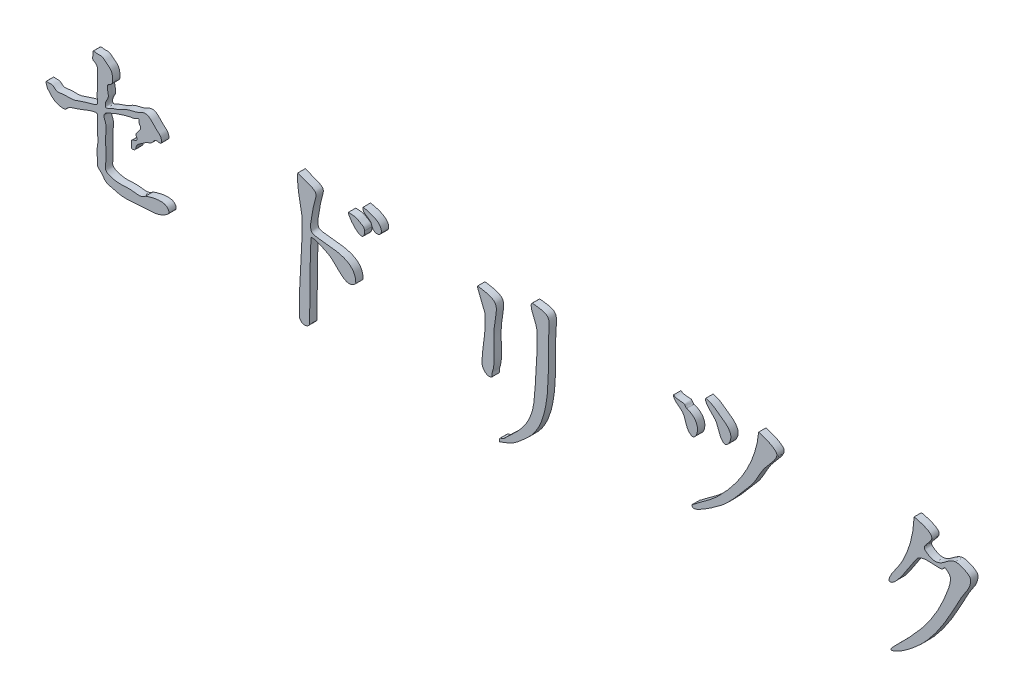
from build123d import *

# Parameters (mm, degrees)
BOSS_EXTRU_1_DEPTH    = 10
BOSS_EXTRU_1_2_DEPTH  = 10
BOSS_EXTRU_1_3_DEPTH  = 10
BOSS_EXTRU_1_4_DEPTH  = 10
BOSS_EXTRU_1_5_DEPTH  = 10
BOSS_EXTRU_1_6_DEPTH  = 10
BOSS_EXTRU_1_7_DEPTH  = 10
BOSS_EXTRU_1_8_DEPTH  = 10
BOSS_EXTRU_1_9_DEPTH  = 10
BOSS_EXTRU_1_10_DEPTH = 10


with BuildPart() as part:
    # Esquisse2 → Boss.-Extru.1 (new body)
    with BuildSketch(Plane.XY):
        with BuildLine():
            add(Edge.make_bspline(
                [(432.080750122, 148.838499756), (430.771768336, 149.257373927), (428.160674934, 149.210542362), (428.080750122, 147.838499756), (426.103139416, 113.889515966), (427.07081187, 79.830619757), (426.080750122, 45.838499756), (425.989196898, 42.695172395), (421.144879507, 40.131392974), (418.080750122, 40.838499756), (415.08626914, 41.529533829), (412.129914733, 44.765711562), (412.080750122, 47.838499756), (411.451135896, 87.189388879), (416.328266772, 126.483352387), (416.080750122, 165.838499756), (416.07848798, 166.198180437), (407.615717471, 203.513336499), (410.080750122, 215.838499756)],
                knots=[6, 6, 6, 6, 7, 7, 7, 8, 8, 8, 9, 9, 9, 10, 10, 10, 11, 11, 11, 12, 12, 12, 12], degree=3))
            add(Edge.make_bspline(
                [(410.080750122, 215.838499756), (444.705544929, 203.247665281), (434.174591037, 207.813079343), (430.080750122, 179.838499756), (428.966433901, 172.224005578), (426.350321845, 164.33702229), (428.080750122, 156.838499756), (430.502416465, 146.344612272), (489.080750122, 160.294699575), (489.080750122, 124.838499756), (489.080750122, 124.367095235), (488.414083456, 124.171833089), (488.080750122, 123.838499756), (475.6538721, 111.411621734), (464.034223561, 132.960737364), (453.080750122, 139.838499756), (446.631028121, 143.888325198), (439.334196328, 146.51739697), (432.080750122, 148.838499756)],
                knots=[0, 0, 0, 0, 1, 1, 1, 2, 2, 2, 3, 3, 3, 4, 4, 4, 5, 5, 5, 6, 6, 6, 6], degree=3))
        make_face()
    extrude(amount=BOSS_EXTRU_1_DEPTH)


with BuildPart() as body_2:
    # Esquisse2 → Boss.-Extru.1 2 (new body)
    with BuildSketch(Plane.XY):
        with BuildLine():
            add(Edge.make_bspline(
                [(501.080750122, 192.838499756), (501.080750122, 171.074934244), (477.871223683, 199.000393997), (479.080750122, 203.838499756)],
                knots=[2, 2, 2, 2, 3, 3, 3, 3], degree=3))
            add(Edge.make_bspline(
                [(479.080750122, 203.838499756), (487.057047526, 203.11338181), (488.454293708, 203.922804032), (493.080750122, 200.838499756), (495.862376364, 198.984082261), (501.080750122, 197.4302739), (501.080750122, 192.838499756)],
                knots=[0, 0, 0, 0, 1, 1, 1, 2, 2, 2, 2], degree=3))
        make_face()
    extrude(amount=BOSS_EXTRU_1_2_DEPTH)


with BuildPart() as body_3:
    # Esquisse2 → Boss.-Extru.1 3 (new body)
    with BuildSketch(Plane.XY):
        with BuildLine():
            add(Edge.make_bspline(
                [(513.080750122, 199.838499756), (512.204955469, 200.539135478), (510.08020419, 206.839045688), (509.080750122, 207.838499756), (504.113950608, 212.80529927), (497.444544286, 213.293676412), (499.080750122, 219.838499756)],
                knots=[2, 2, 2, 2, 3, 3, 3, 4, 4, 4, 4], degree=3))
            add(Edge.make_bspline(
                [(499.080750122, 219.838499756), (504.643768447, 219.043782852), (513.169320977, 216.446119186), (517.080750122, 213.838499756), (530.447689072, 204.927207123), (521.54230902, 193.069252638), (513.080750122, 199.838499756)],
                knots=[0, 0, 0, 0, 1, 1, 1, 2, 2, 2, 2], degree=3))
        make_face()
    extrude(amount=BOSS_EXTRU_1_3_DEPTH)


with BuildPart() as body_4:
    # Esquisse2 → Boss.-Extru.1 4 (new body)
    with BuildSketch(Plane.XY):
        with BuildLine():
            add(Edge.make_bspline(
                [(674.080750122, 106.838499756), (667.289356089, 103.442802739), (661.080750122, 111.57228509), (661.080750122, 116.838499756), (661.080750122, 137.300377055), (667.220707502, 155.438925958), (665.080750122, 176.838499756), (664.454868291, 183.097318069), (654.002069655, 201.602458354), (655.080750122, 204.838499756)],
                knots=[3, 3, 3, 3, 4, 4, 4, 5, 5, 5, 6, 6, 6, 6], degree=3))
            add(Edge.make_bspline(
                [(655.080750122, 204.838499756), (693.790665267, 199.999760362), (677.080750122, 190.236665998), (677.080750122, 155.838499756), (677.080750122, 141.489670922), (679.618248209, 126.450994016), (675.080750122, 112.838499756), (674.439570653, 110.914961349), (675.894279523, 107.745264456), (674.080750122, 106.838499756)],
                knots=[0, 0, 0, 0, 1, 1, 1, 2, 2, 2, 3, 3, 3, 3], degree=3))
        make_face()
    extrude(amount=BOSS_EXTRU_1_4_DEPTH)


with BuildPart() as body_5:
    # Esquisse2 → Boss.-Extru.1 5 (new body)
    with BuildSketch(Plane.XY):
        with BuildLine():
            add(Edge.make_bspline(
                [(736.080750122, 190.838499756), (735.878931153, 200.223081804), (729.014766845, 208.498332526), (728.080750122, 217.838499756), (727.932418736, 219.321813621), (728.596160184, 221.973462477), (730.080750122, 221.838499756), (754.103191948, 219.654641408), (753.407702976, 216.088886857), (752.080750122, 198.838499756), (749.218452305, 161.628628129), (759.794035762, 94.170899687), (724.080750122, 60.838499756), (704.106463227, 42.195831987), (701.944808029, 42.162521471), (685.080750122, 35.838499756)],
                knots=[5, 5, 5, 5, 6, 6, 6, 7, 7, 7, 8, 8, 8, 9, 9, 9, 10, 10, 10, 10], degree=3))
            add(Edge.make_bspline(
                [(685.080750122, 35.838499756), (685.080750122, 37.171833089), (684.213028291, 38.826157619), (685.080750122, 39.838499756), (686.535963872, 41.536249131), (689.450996288, 41.307518881), (691.080750122, 42.838499756), (708.258288838, 58.974975519), (722.092336613, 70.475576526), (729.080750122, 92.838499756), (731.696213461, 101.20798244), (732.456011034, 110.09215252), (733.080750122, 118.838499756), (734.792162992, 142.79827993), (736.597207577, 166.823228121), (736.080750122, 190.838499756)],
                knots=[0, 0, 0, 0, 1, 1, 1, 2, 2, 2, 3, 3, 3, 4, 4, 4, 5, 5, 5, 5], degree=3))
        make_face()
    extrude(amount=BOSS_EXTRU_1_5_DEPTH)


with BuildPart() as body_6:
    # Esquisse2 → Boss.-Extru.1 6 (new body)
    with BuildSketch(Plane.XY):
        with BuildLine():
            add(Edge.make_bspline(
                [(940.080750122, 202.838499756), (963.17137518, 195.141624736), (953.749672127, 171.170930954), (947.080750122, 173.838499756), (938.475268795, 177.280692286), (939.331320695, 190.004532453), (934.080750122, 195.838499756), (929.969050066, 200.407055373), (922.080750122, 203.692136784), (922.080750122, 209.838499756)],
                knots=[3, 3, 3, 3, 4, 4, 4, 5, 5, 5, 6, 6, 6, 6], degree=3))
            add(Edge.make_bspline(
                [(922.080750122, 209.838499756), (923.526953174, 209.476948993), (924.618986757, 208.130852429), (926.080750122, 207.838499756), (929.365654731, 207.181518834), (932.795845513, 207.495480677), (936.080750122, 206.838499756), (937.929750776, 206.468699625), (938.29189574, 203.43478455), (940.080750122, 202.838499756)],
                knots=[0, 0, 0, 0, 1, 1, 1, 2, 2, 2, 3, 3, 3, 3], degree=3))
        make_face()
    extrude(amount=BOSS_EXTRU_1_6_DEPTH)


with BuildPart() as body_7:
    # Esquisse2 → Boss.-Extru.1 7 (new body)
    with BuildSketch(Plane.XY):
        with BuildLine():
            add(Edge.make_bspline(
                [(992.080750122, 186.838499756), (984.701047098, 188.314440361), (983.107646144, 203.804879729), (979.080750122, 208.838499756), (975.412277877, 213.424090062), (963.492058054, 222.661115618), (966.080750122, 227.838499756)],
                knots=[3, 3, 3, 3, 4, 4, 4, 5, 5, 5, 5], degree=3))
            add(Edge.make_bspline(
                [(966.080750122, 227.838499756), (970.869560247, 227.040364735), (975.579325444, 224.464568264), (979.080750122, 221.838499756), (989.344386267, 214.140772647), (1007.612519731, 205.636154168), (997.080750122, 189.838499756), (996.002606735, 188.221284676), (993.986656372, 186.457318506), (992.080750122, 186.838499756)],
                knots=[0, 0, 0, 0, 1, 1, 1, 2, 2, 2, 3, 3, 3, 3], degree=3))
        make_face()
    extrude(amount=BOSS_EXTRU_1_7_DEPTH)


with BuildPart() as body_8:
    # Esquisse2 → Boss.-Extru.1 8 (new body)
    with BuildSketch(Plane.XY):
        with BuildLine():
            add(Edge.make_bspline(
                [(973.080750122, 101.838499756), (955.315186437, 89.994790632), (948.013809326, 87.173203736), (947.080750122, 91.838499756), (946.803400024, 93.225250246), (948.976434861, 93.955047547), (950.080750122, 94.838499756), (960.650559355, 103.294347142), (972.348551982, 110.43070822), (982.080750122, 119.838499756), (1009.938524835, 146.767681978), (1034.787048033, 184.314074681), (1038.080750122, 223.838499756)],
                knots=[5, 5, 5, 5, 6, 6, 6, 7, 7, 7, 8, 8, 8, 9, 9, 9, 9], degree=3))
            add(Edge.make_bspline(
                [(1038.080750122, 223.838499756), (1045.199518492, 221.702869245), (1057.480519018, 217.972141228), (1062.080750122, 211.838499756), (1066.673561297, 205.714751523), (1051.038800565, 192.425101864), (1045.080750122, 183.838499756), (1038.332778104, 174.113481259), (1033.929001475, 162.699428703), (1026.080750122, 153.838499756), (1016.059384312, 142.524054486), (1006.869526062, 130.423713885), (996.080750122, 119.838499756), (989.13154495, 113.020411662), (981.181082499, 107.23872134), (973.080750122, 101.838499756)],
                knots=[0, 0, 0, 0, 1, 1, 1, 2, 2, 2, 3, 3, 3, 4, 4, 4, 5, 5, 5, 5], degree=3))
        make_face()
    extrude(amount=BOSS_EXTRU_1_8_DEPTH)


with BuildPart() as body_9:
    # Esquisse2 → Boss.-Extru.1 9 (new body)
    with BuildSketch(Plane.XY):
        with BuildLine():
            add(Edge.make_bspline(
                [(1224.080750122, 64.838499756), (1252.215254444, 92.25160653), (1275.58949357, 117.148681605), (1291.080750122, 153.838499756), (1293.564238109, 159.720444987), (1303.010193511, 180.416112028), (1298.080750122, 185.838499756), (1289.217417241, 195.588165925), (1291.619869973, 187.372513856), (1287.080750122, 186.838499756), (1276.440691586, 185.586728163), (1263.788816934, 190.079280971), (1255.080750122, 183.838499756), (1251.084404882, 180.974452333), (1226.944021253, 135.742580741), (1217.080750122, 136.838499756), (1214.409767842, 137.135275565), (1216.850028768, 142.44945242), (1218.080750122, 144.838499756), (1222.611718301, 153.633908572), (1229.592063931, 161.021437594), (1234.080750122, 169.838499756), (1244.88089933, 191.053078558), (1248.667479067, 207.226162876), (1250.080750122, 229.838499756)],
                knots=[8, 8, 8, 8, 9, 9, 9, 10, 10, 10, 11, 11, 11, 12, 12, 12, 13, 13, 13, 14, 14, 14, 15, 15, 15, 16, 16, 16, 16], degree=3))
            add(Edge.make_bspline(
                [(1250.080750122, 229.838499756), (1251.63022695, 229.39579209), (1274.671840414, 224.522673553), (1274.080750122, 216.838499756), (1273.543266272, 209.851209707), (1259.63387091, 202.247878165), (1265.080750122, 197.838499756), (1288.594478386, 178.803576875), (1294.053216135, 211.156782059), (1313.080750122, 203.838499756), (1318.619998813, 201.70801949), (1327.225459068, 198.771566546), (1327.080750122, 192.838499756), (1326.808139979, 181.661483888), (1317.190935402, 172.782644083), (1312.080750122, 162.838499756), (1297.798211422, 135.045451475), (1282.35835008, 106.750893157), (1260.080750122, 84.838499756), (1257.003927061, 81.812116417), (1232.763305727, 59.326237138), (1219.080750122, 56.838499756), (1215.986813399, 56.275965806), (1221.828451315, 62.6439522), (1224.080750122, 64.838499756)],
                knots=[0, 0, 0, 0, 1, 1, 1, 2, 2, 2, 3, 3, 3, 4, 4, 4, 5, 5, 5, 6, 6, 6, 7, 7, 7, 8, 8, 8, 8], degree=3))
        make_face()
    extrude(amount=BOSS_EXTRU_1_9_DEPTH)


with BuildPart() as body_10:
    # Esquisse2 → Boss.-Extru.1 10 (new body)
    with BuildSketch(Plane.XY):
        with BuildLine():
            add(Edge.make_bspline(
                [(71.075421494, 142.959669144), (75.406675635, 135.430914206), (84.661989741, 131.023884336), (93.27491994, 132.328923409)],
                knots=[0, 0, 0, 0, 1, 1, 1, 1], degree=3))
            add(Edge.make_bspline(
                [(93.27491994, 132.328923409), (97.153171329, 137.994252064), (107.023213135, 139.838831977), (120.173743393, 145.316717918), (127.968837828, 148.388726831), (138.30283699, 150.425636976), (136.770992635, 142.913375551), (137.186551016, 136.963712563), (136.916085129, 129.779783374), (137.390356099, 121.714122438), (137.843535079, 112.450940635), (134.837115301, 102.883049635), (138.193176702, 94.726521633), (135.799033141, 86.893182778), (143.496797881, 82.195390001), (146.993916264, 74.227627079), (157.324418811, 71.420805191), (169.925170552, 67.713330583), (185.312146892, 68.590210636), (201.749977897, 70.174322762), (216.571175565, 69.918745365), (227.431899373, 74.562426573), (236.029745364, 80.080180203), (231.553836718, 88.193531584), (218.765102194, 89.784986439), (209.20983219, 86.868303511), (202.396398216, 84.490567603)],
                knots=[0, 0, 0, 0, 0.073359985, 0.118542653, 0.164390314, 0.187974318, 0.211345649, 0.231205862, 0.264719973, 0.294536142, 0.328050253, 0.374882197, 0.408127887, 0.42926584, 0.461847526, 0.498877971, 0.528382464, 0.581972851, 0.657689916, 0.707479896, 0.780976943, 0.826617642, 0.856459637, 0.879780858, 0.914735151, 1, 1, 1, 1], degree=3))
            add(Edge.make_bspline(
                [(202.396398216, 84.490567603), (196.733973172, 79.203641418), (186.837765677, 82.529970664), (173.678562052, 82.000231605), (163.91422851, 81.472700362), (155.483881866, 83.517652811), (146.421042021, 87.319148653), (148.975811592, 97.474429661), (148.04972989, 107.152468006), (148.519285783, 119.072474377), (147.720380765, 131.069908577), (149.978632752, 142.420375593), (144.361521102, 150.652434662), (148.158232805, 155.808618717), (154.513353555, 158.513842861), (167.074624007, 164.198234963), (179.314032585, 167.265479576), (187.388286591, 168.598526504)],
                knots=[0, 0, 0, 0, 0.117306734, 0.175749391, 0.239847789, 0.290152454, 0.339313681, 0.388330104, 0.45143824, 0.522182641, 0.601363016, 0.669231908, 0.727308533, 0.750320905, 0.773942982, 0.851673708, 1, 1, 1, 1], degree=3))
            add(Edge.make_bspline(
                [(187.388286591, 168.598526504), (196.229759189, 174.277126524), (191.145679933, 167.652342453), (199.97800842, 159.807149248), (187.059689022, 153.034723183), (190.20230752, 148.838499756)],
                knots=[0, 0, 0, 0, 0.327364246, 0.495940631, 1, 1, 1, 1], degree=3))
            add(Edge.make_bspline(
                [(190.20230752, 148.838499756), (193.338657949, 142.389031556), (181.27178661, 143.99939923), (184.413063134, 136.425679643), (182.161613075, 130.939105774), (189.650094151, 131.199639209), (189.005777211, 139.142136887), (197.065641422, 143.265018378), (203.261563125, 149.119475239), (212.030134821, 151.03120057), (215.283502073, 159.446849338), (225.257467911, 154.804127642), (224.123267642, 165.805388014), (217.519117525, 170.021765484), (212.175724738, 176.159455675), (206.567315015, 181.587655122), (199.361672928, 182.436947667), (192.121399641, 177.390113732), (182.814466036, 176.241381915), (173.631659911, 172.84507147), (165.236828462, 167.521629221), (157.416079995, 166.309221236), (146.918723793, 159.699516221), (147.910001248, 170.413634629), (154.725881285, 176.874070709), (147.358957398, 189.975160969), (158.231115168, 193.332890388), (158.051034761, 202.534177071), (155.439039999, 211.108585115), (148.707943964, 215.011891969), (142.974587771, 220.876680132), (137.09684717, 219.122896529), (129.601011948, 221.567790088), (131.483434306, 214.938139912), (129.214370102, 209.790912502), (134.520088318, 207.802748363), (137.259963214, 204.205766997), (136.493857816, 198.787302466), (136.865914719, 191.801672571), (136.65720969, 183.58053061), (136.88816241, 174.77325611), (136.179497847, 167.758179261), (138.260758801, 159.474242105), (130.23221487, 157.106829192), (122.976618808, 155.485896411), (112.926211659, 151.675258731), (102.145837077, 148.062244767), (90.729371854, 149.640340363), (81.136958321, 146.129842359), (75.901952373, 153.235576514), (71.402427218, 151.848720567), (65.828466792, 153.53361089), (68.461324025, 147.099056644), (68.546574022, 144.450302689), (71.075421494, 142.959669144)],
                knots=[0, 0, 0, 0, 0.027685396, 0.040614372, 0.051927226, 0.061623957, 0.079346119, 0.098806804, 0.126060374, 0.146008079, 0.164292412, 0.182069754, 0.200655157, 0.21951953, 0.244660488, 0.263087114, 0.278525097, 0.296247258, 0.328991182, 0.34970341, 0.372472958, 0.402642973, 0.421298509, 0.437459729, 0.459530299, 0.496805708, 0.50708797, 0.536073615, 0.552579467, 0.576169335, 0.594678394, 0.609223492, 0.62457665, 0.634914241, 0.650420626, 0.660236586, 0.672547753, 0.682885343, 0.700976126, 0.72725911, 0.746652574, 0.768470221, 0.784631441, 0.801981246, 0.821188636, 0.845976492, 0.884232809, 0.906858517, 0.935948713, 0.95172957, 0.962234363, 0.972739156, 0.981930941, 1, 1, 1, 1], degree=3))
        make_face()
    extrude(amount=BOSS_EXTRU_1_10_DEPTH)


solid = Compound([part.part, body_2.part, body_3.part, body_4.part, body_5.part, body_6.part, body_7.part, body_8.part, body_9.part, body_10.part])
